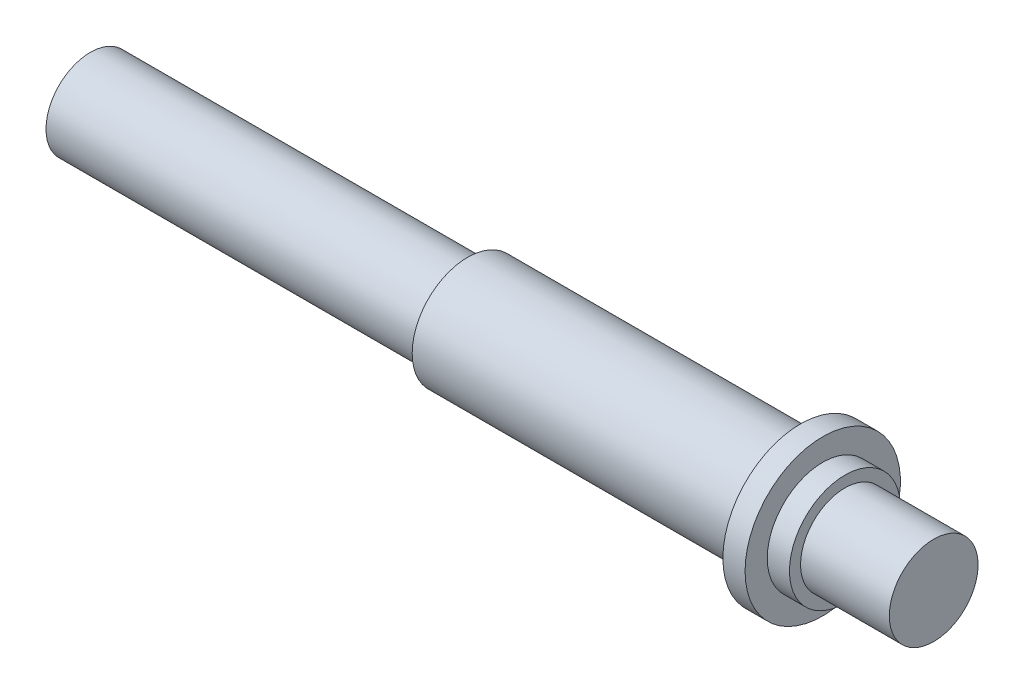
from build123d import *


with BuildPart() as part:
    # 草图1 → 旋转1 (revolve)
    with BuildSketch(Plane.XY):
        Polygon((-54.836952271, 0), (-54.836952271, 2), (-37.836952271, 2), (-37.836952271, 2.5), (-22.836952271, 2.5), (-22.836952271, 3.5), (-21.836952271, 3.5), (-21.836952271, 2.5), (-20.836952271, 2.5), (-20.836952271, 2), (-16.836952271, 2), (-16.836952271, 0), align=None)
    revolve(axis=Axis((-56.844533841, 0, 0), (1, 0, 0)))


solid = part.part
